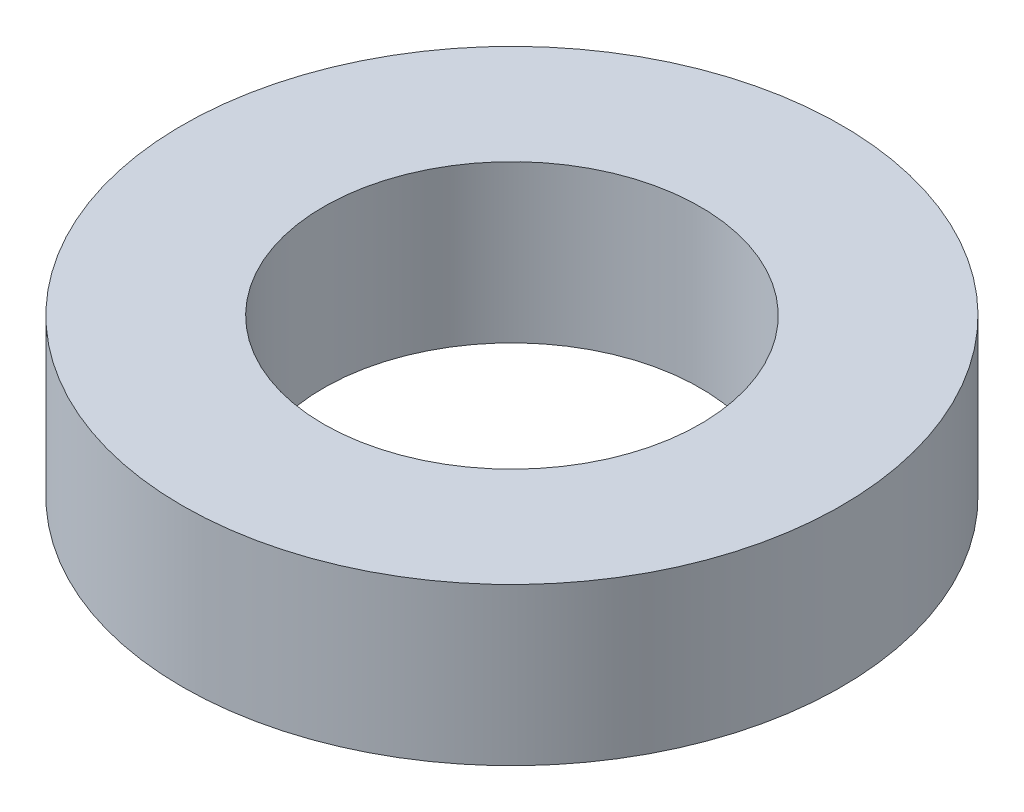
from build123d import *

# Parameters (mm, degrees)
SKETCH1_W = 4.5
SKETCH1_H = 5


with BuildPart() as part:
    # Sketch1 → Revolve1 (revolve)
    with BuildSketch(Plane.XY):
        with Locations((-8.25, 0)):
            Rectangle(SKETCH1_W, SKETCH1_H)
    revolve(axis=Axis((0, 55, 0), (0, -1, 0)))


solid = part.part
